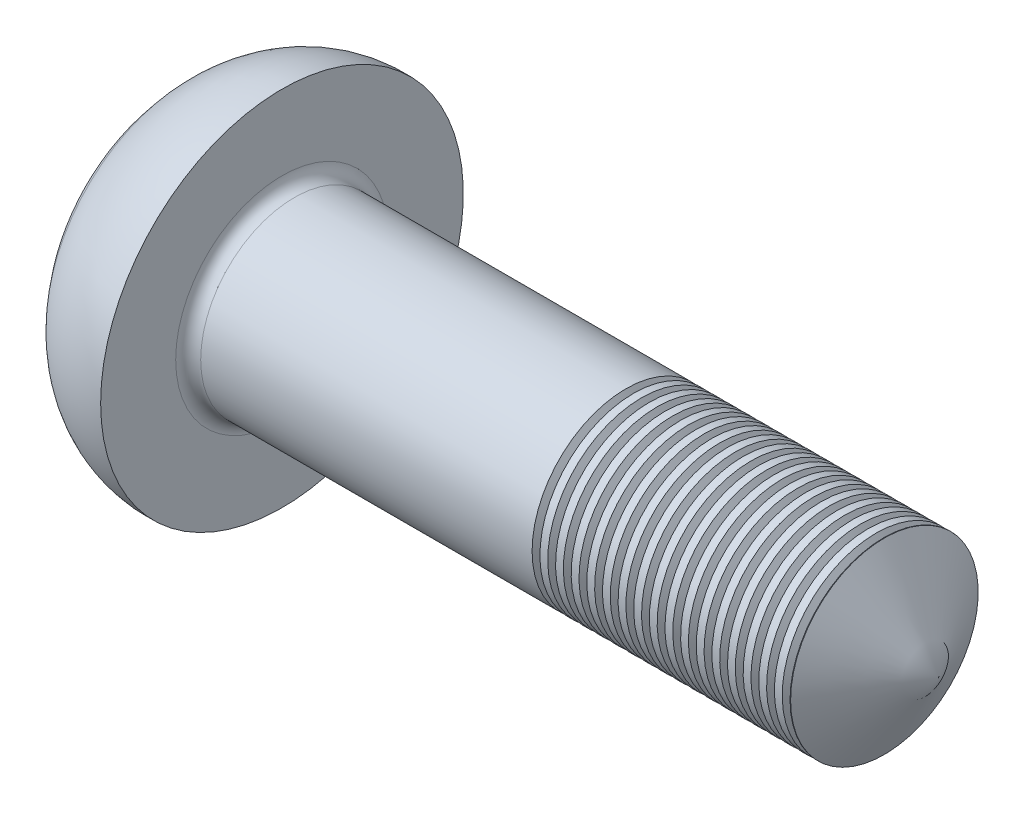
from build123d import *

# Parameters (mm, degrees)
FILLET2_R        = 0.2
LPATTERN10_COUNT = 20
LPATTERN10_PITCH = 0.25


with BuildPart() as part:
    # Sketch1 → Revolve1 (revolve)
    with BuildSketch(Plane(origin=(0, 0, 0), x_dir=(1, 0, 0), z_dir=(0, 1, 0))):
        with BuildLine():
            Line((2.37, 1.5), (12.87, 1.5))
            Line((12.87, 1.5), (12.87, 0))
            Line((12.87, 0), (0, 0))
            ThreePointArc((0, 0), (0.224879408, 1.215980768), (0.869770135, 2.271109163))
            ThreePointArc((0.869770135, 2.271109163), (1.549177667, 2.754228297), (2.37, 2.9))
            Line((2.37, 2.9), (2.37, 1.5))
        make_face()
    revolve(axis=Axis((-13.629268293, 0, 0), (1, 0, 0)))

    # Fillet2
    fillet2_edges = [part.edges().sort_by_distance(p)[0] for p in [
        (2.37, 0, 1.5),
    ]]
    fillet(fillet2_edges, radius=FILLET2_R)

    # Sketch4 → Cut-Revolve1 (revolve, cut)
    with BuildSketch(Plane(origin=(0, 0, 0), x_dir=(1, 0, 0), z_dir=(0, 1, 0))):
        Polygon((13.603454633, 0), (13.603454633, 21), (0.745644347, 21), (12.87, 0), align=None)
    revolve(axis=Axis((4.782773752, 0, 0), (1, 0, 0)), mode=Mode.SUBTRACT)

    # Sketch2 → Cut-Loft1 section 0
    with BuildSketch(Plane(origin=(0, 0, 0), x_dir=(0, 0, -1), z_dir=(1, 0, 0)), mode=Mode.PRIVATE) as cut_loft1_s0:
        Polygon((-0.4625, 0.4625), (-1.85, 0.4625), (-1.85, -0.4625), (-0.4625, -0.4625), (-0.4625, -1.85), (0.4625, -1.85), (0.4625, -0.4625), (1.85, -0.4625), (1.85, 0.4625), (0.4625, 0.4625), (0.4625, 1.85), (-0.4625, 1.85), align=None)
    loft([Vertex(2.62, 0, 0), cut_loft1_s0.sketch], mode=Mode.SUBTRACT)

    # Sketch6 → Cut-Revolve10 (revolve, cut)
    with BuildSketch(Plane.XY):
        Polygon((7.87, 1.7), (7.995, 1.7), (7.995, 1.5), (7.9325, 1.391746825), (7.87, 1.5), align=None)
    cut_revolve10 = revolve(axis=Axis((10.774329131, 0, 0), (-1, 0, 0)), mode=Mode.SUBTRACT)

    # LPattern10: Cut-Revolve10 ×20
    with Locations(*[(i * LPATTERN10_PITCH, 0, 0) for i in range(1, LPATTERN10_COUNT)]):
        add(cut_revolve10, mode=Mode.SUBTRACT)


solid = part.part
